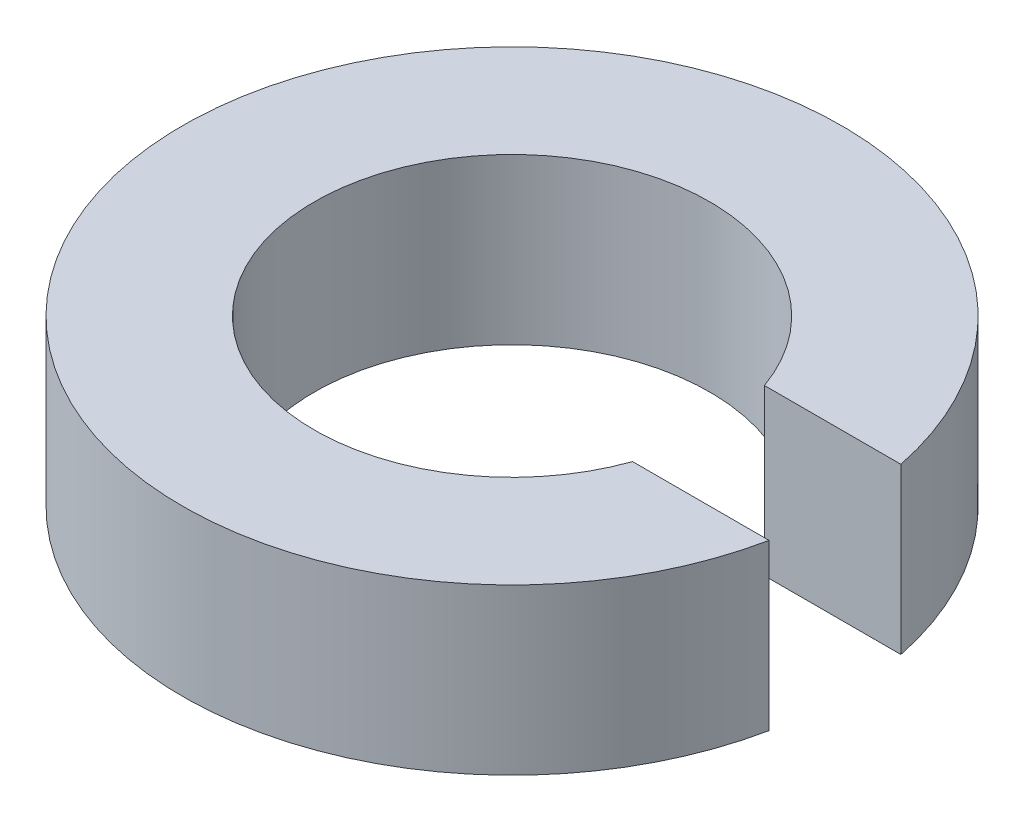
from build123d import *

# Parameters (mm, degrees)
BOSS_EXTRUDE1_DEPTH = 10


with BuildPart() as part:
    # Sketch1 → Boss-Extrude1 (new body)
    with BuildSketch(Plane(origin=(0, 0, 0), x_dir=(1, 0, 0), z_dir=(0, 1, 0))):
        with BuildLine():
            Line((131.313708499, 24), (139.595917942, 24))
            ThreePointArc((139.595917942, 24), (100, 20), (139.595917942, 16))
            Line((139.595917942, 16), (131.313708499, 16))
            ThreePointArc((131.313708499, 16), (108, 20), (131.313708499, 24))
        make_face()
    extrude(amount=BOSS_EXTRUDE1_DEPTH)


solid = part.part
